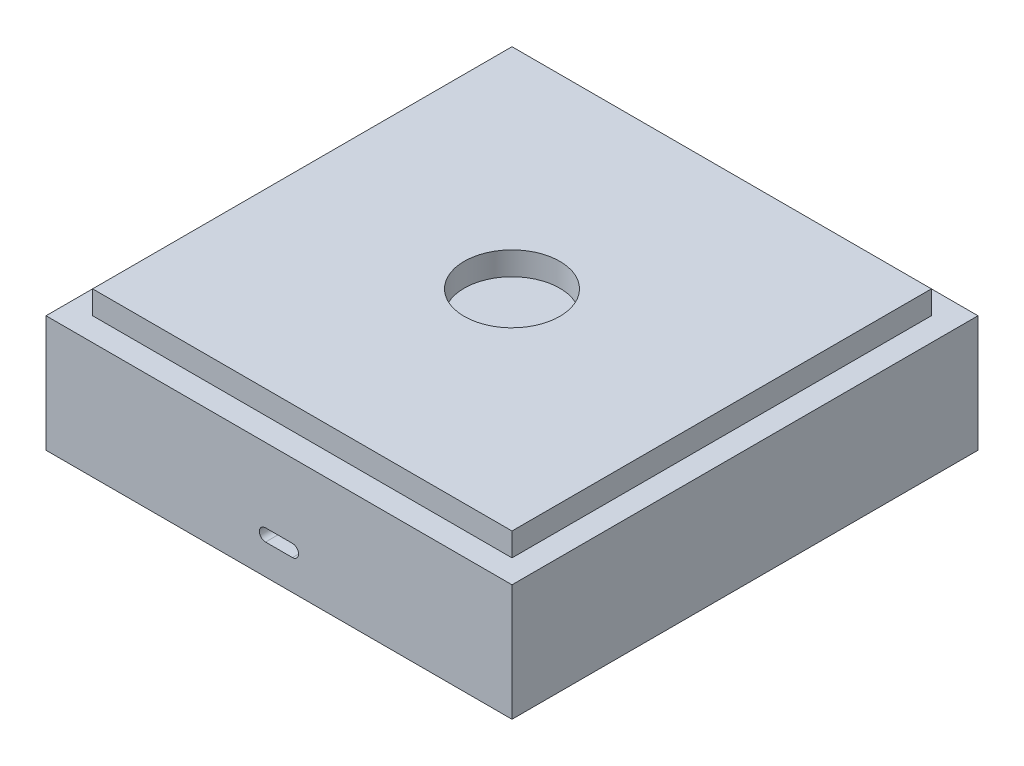
from build123d import *

# Parameters (mm, degrees)
SKETCH1_W           = 100
SKETCH1_H           = 100
SKETCH1_W_2         = 90
SKETCH1_H_2         = 90
BOSS_EXTRUDE2_DEPTH = 25
SKETCH1_3_W         = 90
SKETCH1_3_H         = 90
BOSS_EXTRUDE3_DEPTH = 5
SKETCH3_W           = 90
SKETCH3_H           = 90
SKETCH3_R           = 10.25
BOSS_EXTRUDE7_DEPTH = 5
CUT_EXTRUDE1_DEPTH  = 10


with BuildPart() as part:
    # Sketch1 → Boss-Extrude2 (new body)
    with BuildSketch(Plane(origin=(0, 0, 0), x_dir=(1, 0, 0), z_dir=(0, 1, 0))):
        with Locations((50, -50)):
            Rectangle(SKETCH1_W, SKETCH1_H)
        with Locations((50, -50)):
            Rectangle(SKETCH1_W_2, SKETCH1_H_2, mode=Mode.SUBTRACT)
    extrude(amount=BOSS_EXTRUDE2_DEPTH)

    # Sketch1_3 → Boss-Extrude3 (add)
    with BuildSketch(Plane(origin=(0, 0, 0), x_dir=(1, 0, 0), z_dir=(0, 1, 0))):
        with Locations((50, -50)):
            Rectangle(SKETCH1_3_W, SKETCH1_3_H)
    extrude(amount=BOSS_EXTRUDE3_DEPTH)

    # Sketch5 → Cut-Extrude1 (cut)
    with BuildSketch(Plane.XY.offset(100)):
        with BuildLine():
            Line((52.89, 9.14), (47.11, 9.14))
            ThreePointArc((47.11, 9.14), (45.79, 7.82), (47.11, 6.5))
            Line((47.11, 6.5), (52.89, 6.5))
            ThreePointArc((52.89, 6.5), (54.21, 7.82), (52.89, 9.14))
        make_face()
    extrude(amount=-CUT_EXTRUDE1_DEPTH, mode=Mode.SUBTRACT)


with BuildPart() as body_2:
    # Sketch3 → Boss-Extrude7 (new body)
    with BuildSketch(Plane(origin=(0, 25, 0), x_dir=(1, 0, 0), z_dir=(0, 1, 0))):
        with Locations((50, -50)):
            Rectangle(SKETCH3_W, SKETCH3_H)
        with Locations((50, -50)):
            Circle(SKETCH3_R, mode=Mode.SUBTRACT)
    extrude(amount=BOSS_EXTRUDE7_DEPTH)


solid = Compound([part.part, body_2.part])
